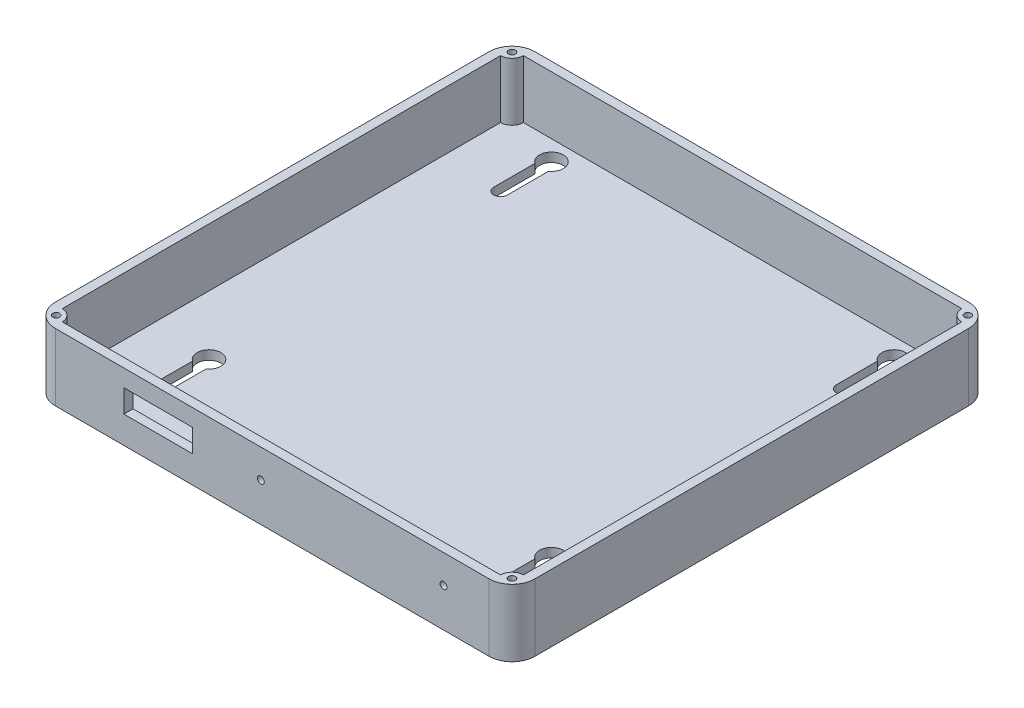
from build123d import *

# Parameters (mm, degrees)
SKETCH1_W            = 210
SKETCH1_H            = 210
BASE_DEPTH           = 4
WALLS_START          = 4
SKETCH1_3_W          = 210
SKETCH1_3_H          = 210
SKETCH1_3_W_2        = 202
SKETCH1_3_H_2        = 202
WALLS_DEPTH          = 25.4
SCREWMOUNTS_DEPTH    = 25.4
SKETCH2_5_R          = 1.5
SCREWHOLES_DEPTH     = 12.5
ROUNDEDCORNERS_R     = 10
BACKHOLEMOUNTS_DEPTH = 4
SKETCH4_R            = 1.5
SKETCH4_W            = 30
SKETCH4_H            = 10
BATTERYPACK_DEPTH    = 4


with BuildPart() as part:
    # Sketch1 → Base (new body)
    with BuildSketch(Plane(origin=(0, 0, 0), x_dir=(1, 0, 0), z_dir=(0, 1, 0))):
        Rectangle(SKETCH1_W, SKETCH1_H)
    extrude(amount=BASE_DEPTH)

    # Sketch1_3 → Walls (add)
    with BuildSketch(Plane(origin=(0, 0, 0), x_dir=(1, 0, 0), z_dir=(0, 1, 0)).offset(WALLS_START)):
        Rectangle(SKETCH1_3_W, SKETCH1_3_H)
        Rectangle(SKETCH1_3_W_2, SKETCH1_3_H_2, mode=Mode.SUBTRACT)
    extrude(amount=WALLS_DEPTH)

    # Sketch2 → ScrewMounts (add)
    with BuildSketch(Plane(origin=(0, 29.4, 0), x_dir=(1, 0, 0), z_dir=(0, 1, 0))):
        with BuildLine():
            Line((-101, 101), (-101, 96))
            ThreePointArc((-101, 96), (-97.464466094, 97.464466094), (-96, 101))
            Line((-96, 101), (-101, 101))
        make_face()
        with BuildLine():
            Line((-101, -101), (-96, -101))
            ThreePointArc((-96, -101), (-97.464466094, -97.464466094), (-101, -96))
            Line((-101, -96), (-101, -101))
        make_face()
        with BuildLine():
            Line((101, 101), (96, 101))
            ThreePointArc((96, 101), (97.464466094, 97.464466094), (101, 96))
            Line((101, 96), (101, 101))
        make_face()
        with BuildLine():
            Line((101, -101), (101, -96))
            ThreePointArc((101, -96), (97.464466094, -97.464466094), (96, -101))
            Line((96, -101), (101, -101))
        make_face()
    extrude(amount=-SCREWMOUNTS_DEPTH)

    # Sketch2_5 → ScrewHoles (cut)
    with BuildSketch(Plane(origin=(0, 29.4, 0), x_dir=(1, 0, 0), z_dir=(0, 1, 0))):
        with Locations((-99.833273811, 99.833273811)):
            Circle(SKETCH2_5_R)
        with Locations((-99.833273811, -99.833273811)):
            Circle(SKETCH2_5_R)
        with Locations((99.833273811, 99.833273811)):
            Circle(SKETCH2_5_R)
        with Locations((99.833273811, -99.833273811)):
            Circle(SKETCH2_5_R)
    extrude(amount=-SCREWHOLES_DEPTH, mode=Mode.SUBTRACT)

    # RoundedCorners
    roundedcorners_edges = [part.edges().sort_by_distance(p)[0] for p in [
        (-105, 14.7, 105),
        (105, 14.7, 105),
        (105, 14.7, -105),
        (-105, 14.7, -105),
    ]]
    fillet(roundedcorners_edges, radius=ROUNDEDCORNERS_R)

    # Sketch3 → BackHoleMounts (cut)
    with BuildSketch(Plane.XZ):
        with BuildLine():
            Line((-77.985, 80), (-77.985, 61.974012195))
            ThreePointArc((-77.985, 61.974012195), (-75, 52.505), (-72.015, 61.974012195))
            Line((-72.015, 61.974012195), (-72.015, 80))
            ThreePointArc((-72.015, 80), (-75, 82.985), (-77.985, 80))
        make_face()
        with BuildLine():
            Line((77.985, 80), (77.985, 61.974012195))
            ThreePointArc((77.985, 61.974012195), (75, 52.505), (72.015, 61.974012195))
            Line((72.015, 61.974012195), (72.015, 80))
            ThreePointArc((72.015, 80), (75, 82.985), (77.985, 80))
        make_face()
        with BuildLine():
            Line((72.015, -70), (72.015, -88.025987805))
            ThreePointArc((72.015, -88.025987805), (75, -97.495), (77.985, -88.025987805))
            Line((77.985, -88.025987805), (77.985, -70))
            ThreePointArc((77.985, -70), (75, -67.015), (72.015, -70))
        make_face()
        with BuildLine():
            Line((-77.985, -70), (-77.985, -88.025987805))
            ThreePointArc((-77.985, -88.025987805), (-75, -97.495), (-72.015, -88.025987805))
            Line((-72.015, -88.025987805), (-72.015, -70))
            ThreePointArc((-72.015, -70), (-75, -67.015), (-77.985, -70))
        make_face()
    extrude(amount=-BACKHOLEMOUNTS_DEPTH, mode=Mode.SUBTRACT)

    # Sketch4 → BatteryPack (cut)
    with BuildSketch(Plane.XY.offset(105)):
        with Locations((75, 16.9)):
            Circle(SKETCH4_R)
        with Locations((-5, 16.9)):
            Circle(SKETCH4_R)
        with Locations((-50, 16.9)):
            Rectangle(SKETCH4_W, SKETCH4_H)
    extrude(amount=-BATTERYPACK_DEPTH, mode=Mode.SUBTRACT)


solid = part.part
